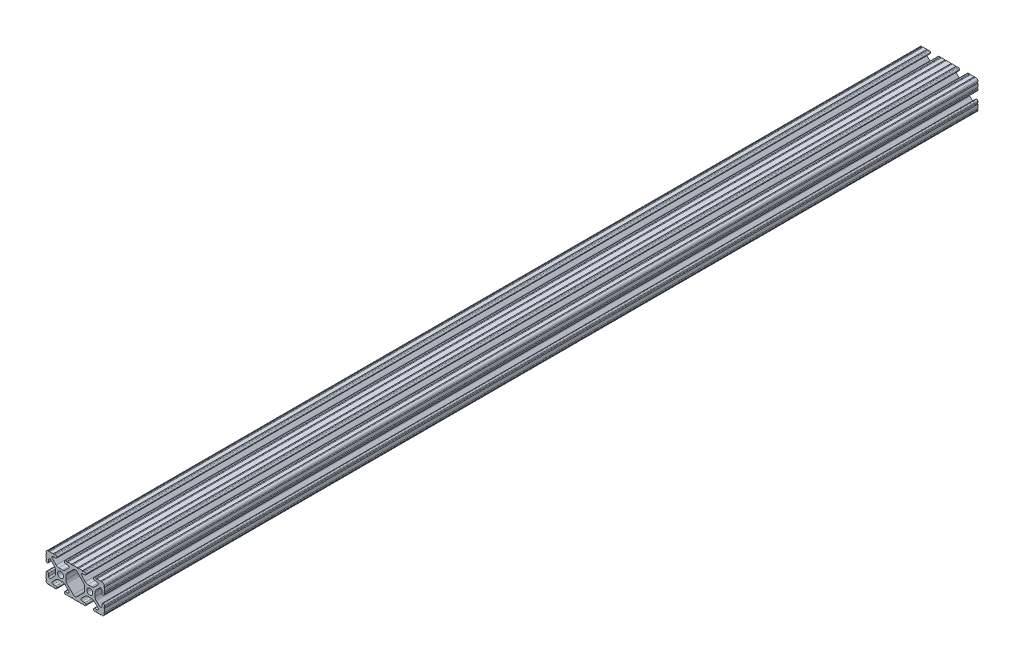
from build123d import *

# Parameters (mm, degrees)
SKETCH1_R      = 2.6035
EXTRUDE1_DEPTH = 760.984


with BuildPart() as part:
    # Sketch1 → Extrude1 (new body)
    with BuildSketch(Plane.XY):
        with BuildLine():
            Line((22.2504, 12.7), (19.03310265, 12.7))
            ThreePointArc((19.03310265, 12.7), (18.52510265, 12.192), (18.01710265, 12.7))
            Line((18.01710265, 12.7), (16.98745015, 12.7))
            ThreePointArc((16.98745015, 12.7), (16.245730386, 12.392769614), (15.9385, 11.65104985))
            Line((15.9385, 11.65104985), (15.9385, 11.53922))
            ThreePointArc((15.9385, 11.53922), (16.245750844, 10.797450844), (16.98752, 10.4902))
            Line((16.98752, 10.4902), (19.116384363, 10.4902))
            ThreePointArc((19.116384363, 10.4902), (20.052502933, 9.869096983), (19.844087081, 8.765172272))
            Line((19.844087081, 8.765172272), (16.618993479, 5.455112286))
            ThreePointArc((16.618993479, 5.455112286), (15.578994274, 4.745442459), (14.344932584, 4.4958))
            Line((14.344932584, 4.4958), (11.083317835, 4.4958))
            ThreePointArc((11.083317835, 4.4958), (9.854330953, 4.743306833), (8.816955189, 5.447238587))
            Line((8.816955189, 5.447238587), (5.564154119, 8.762652677))
            ThreePointArc((5.564154119, 8.762652677), (5.352591412, 9.867473037), (6.289393385, 10.4902))
            Line((6.289393385, 10.4902), (8.41248, 10.4902))
            ThreePointArc((8.41248, 10.4902), (9.154249156, 10.797450844), (9.4615, 11.53922))
            Line((9.4615, 11.53922), (9.4615, 11.65104985))
            ThreePointArc((9.4615, 11.65104985), (9.154269614, 12.392769614), (8.41254985, 12.7))
            Line((8.41254985, 12.7), (7.38288465, 12.7))
            ThreePointArc((7.38288465, 12.7), (6.87488465, 12.192), (6.36688465, 12.7))
            Line((6.36688465, 12.7), (3.14958095, 12.7))
            ThreePointArc((3.14958095, 12.7), (2.64158095, 12.192), (2.13358095, 12.7))
            Line((2.13358095, 12.7), (-2.13358095, 12.7))
            ThreePointArc((-2.13358095, 12.7), (-2.64158095, 12.192), (-3.14958095, 12.7))
            Line((-3.14958095, 12.7), (-6.36689735, 12.7))
            ThreePointArc((-6.36689735, 12.7), (-6.87489735, 12.192), (-7.38289735, 12.7))
            Line((-7.38289735, 12.7), (-8.41254985, 12.7))
            ThreePointArc((-8.41254985, 12.7), (-9.154269614, 12.392769614), (-9.4615, 11.65104985))
            Line((-9.4615, 11.65104985), (-9.4615, 11.53922))
            ThreePointArc((-9.4615, 11.53922), (-9.154249156, 10.797450844), (-8.41248, 10.4902))
            Line((-8.41248, 10.4902), (-6.283641037, 10.4902))
            ThreePointArc((-6.283641037, 10.4902), (-5.297291557, 9.829633109), (-5.532576693, 8.666071843))
            Line((-5.532576693, 8.666071843), (-8.809985098, 5.416263103))
            ThreePointArc((-8.809985098, 5.416263103), (-9.836720513, 4.734920264), (-11.045536121, 4.4958))
            Line((-11.045536121, 4.4958), (-14.354463879, 4.4958))
            ThreePointArc((-14.354463879, 4.4958), (-15.563279487, 4.734920264), (-16.590014902, 5.416263103))
            Line((-16.590014902, 5.416263103), (-19.867423307, 8.666071843))
            ThreePointArc((-19.867423307, 8.666071843), (-20.102708443, 9.829633109), (-19.116358963, 10.4902))
            Line((-19.116358963, 10.4902), (-16.98752, 10.4902))
            ThreePointArc((-16.98752, 10.4902), (-16.245750844, 10.797450844), (-15.9385, 11.53922))
            Line((-15.9385, 11.53922), (-15.9385, 11.65104985))
            ThreePointArc((-15.9385, 11.65104985), (-16.245730386, 12.392769614), (-16.98745015, 12.7))
            Line((-16.98745015, 12.7), (-18.01711535, 12.7))
            ThreePointArc((-18.01711535, 12.7), (-18.52511535, 12.192), (-19.03311535, 12.7))
            Line((-19.03311535, 12.7), (-22.2504, 12.7))
            ThreePointArc((-22.2504, 12.7), (-22.758323491, 12.192000006), (-23.266399977, 12.699846982))
            ThreePointArc((-23.266399977, 12.699846982), (-24.782522516, 12.082522516), (-25.399846982, 10.566399977))
            ThreePointArc((-25.399846982, 10.566399977), (-24.892000006, 10.058323491), (-25.4, 9.5504))
            Line((-25.4, 9.5504), (-25.4, 6.3330836))
            ThreePointArc((-25.4, 6.3330836), (-24.892, 5.8250836), (-25.4, 5.3170836))
            Line((-25.4, 5.3170836), (-25.4, 4.237520184))
            ThreePointArc((-25.4, 4.237520184), (-25.107393763, 3.531106237), (-24.400979816, 3.2385))
            Line((-24.400979816, 3.2385), (-24.23922, 3.2385))
            ThreePointArc((-24.23922, 3.2385), (-23.497450844, 3.545750844), (-23.1902, 4.28752))
            Line((-23.1902, 4.28752), (-23.1902, 6.334741132))
            ThreePointArc((-23.1902, 6.334741132), (-22.556026952, 7.286023527), (-21.434002553, 7.066535717))
            Line((-21.434002553, 7.066535717), (-18.147950853, 3.808156468))
            ThreePointArc((-18.147950853, 3.808156468), (-17.452759693, 2.774838327), (-17.208501877, 1.553619571))
            Line((-17.208501877, 1.553619571), (-17.208501877, -1.695179196))
            ThreePointArc((-17.208501877, -1.695179196), (-17.450738657, -2.911536421), (-18.140486065, -3.942289578))
            Line((-18.140486065, -3.942289578), (-21.431579576, -7.227386226))
            ThreePointArc((-21.431579576, -7.227386226), (-22.55444896, -7.449940594), (-23.1902, -6.498002195))
            Line((-23.1902, -6.498002195), (-23.1902, -4.28752))
            ThreePointArc((-23.1902, -4.28752), (-23.497450844, -3.545750844), (-24.23922, -3.2385))
            Line((-24.23922, -3.2385), (-24.35098, -3.2385))
            ThreePointArc((-24.35098, -3.2385), (-25.092749156, -3.545750844), (-25.4, -4.28752))
            Line((-25.4, -4.28752), (-25.4, -5.3171344))
            ThreePointArc((-25.4, -5.3171344), (-24.892, -5.8251344), (-25.4, -6.3331344))
            Line((-25.4, -6.3331344), (-25.4, -9.5504))
            ThreePointArc((-25.4, -9.5504), (-24.892000006, -10.058323491), (-25.399846982, -10.566399977))
            ThreePointArc((-25.399846982, -10.566399977), (-24.782522516, -12.082522516), (-23.266399977, -12.699846982))
            ThreePointArc((-23.266399977, -12.699846982), (-22.758323491, -12.192000006), (-22.2504, -12.7))
            Line((-22.2504, -12.7), (-19.03308995, -12.7))
            ThreePointArc((-19.03308995, -12.7), (-18.52508995, -12.192), (-18.01708995, -12.7))
            Line((-18.01708995, -12.7), (-16.9874692, -12.7))
            ThreePointArc((-16.9874692, -12.7), (-16.245700044, -12.392749156), (-15.9384492, -11.65098))
            Line((-15.9384492, -11.65098), (-15.9384492, -11.53922))
            ThreePointArc((-15.9384492, -11.53922), (-16.245700044, -10.797450844), (-16.9874692, -10.4902))
            Line((-16.9874692, -10.4902), (-19.116358963, -10.4902))
            ThreePointArc((-19.116358963, -10.4902), (-20.055197748, -9.862578342), (-19.834124023, -8.755124678))
            Line((-19.834124023, -8.755124678), (-16.49660751, -5.423689618))
            ThreePointArc((-16.49660751, -5.423689618), (-15.467274017, -4.736928798), (-14.253591699, -4.4958))
            Line((-14.253591699, -4.4958), (-11.146408301, -4.4958))
            ThreePointArc((-11.146408301, -4.4958), (-9.932725983, -4.736928798), (-8.90339249, -5.423689618))
            Line((-8.90339249, -5.423689618), (-5.565875977, -8.755124678))
            ThreePointArc((-5.565875977, -8.755124678), (-5.344802252, -9.862578342), (-6.283641037, -10.4902))
            Line((-6.283641037, -10.4902), (-8.4125308, -10.4902))
            ThreePointArc((-8.4125308, -10.4902), (-9.154299956, -10.797450844), (-9.4615508, -11.53922))
            Line((-9.4615508, -11.53922), (-9.4615508, -11.65098))
            ThreePointArc((-9.4615508, -11.65098), (-9.154299956, -12.392749156), (-8.4125308, -12.7))
            Line((-8.4125308, -12.7), (-7.38287195, -12.7))
            ThreePointArc((-7.38287195, -12.7), (-6.87487195, -12.192), (-6.36687195, -12.7))
            Line((-6.36687195, -12.7), (-3.14960635, -12.7))
            ThreePointArc((-3.14960635, -12.7), (-2.64160635, -12.192), (-2.13360635, -12.7))
            Line((-2.13360635, -12.7), (2.13360635, -12.7))
            ThreePointArc((2.13360635, -12.7), (2.64159365, -12.1920127), (3.14958095, -12.7))
            Line((3.14958095, -12.7), (6.36691005, -12.7))
            ThreePointArc((6.36691005, -12.7), (6.87491005, -12.192), (7.38291005, -12.7))
            Line((7.38291005, -12.7), (8.4125308, -12.7))
            ThreePointArc((8.4125308, -12.7), (9.154299956, -12.392749156), (9.4615508, -11.65098))
            Line((9.4615508, -11.65098), (9.4615508, -11.53922))
            ThreePointArc((9.4615508, -11.53922), (9.154299956, -10.797450844), (8.4125308, -10.4902))
            Line((8.4125308, -10.4902), (6.289393385, -10.4902))
            ThreePointArc((6.289393385, -10.4902), (5.231590322, -9.783049717), (5.480677245, -8.535265862))
            Line((5.480677245, -8.535265862), (8.597933595, -5.423689618))
            ThreePointArc((8.597933595, -5.423689618), (9.627267088, -4.736928798), (10.840949406, -4.4958))
            Line((10.840949406, -4.4958), (14.102564155, -4.4958))
            ThreePointArc((14.102564155, -4.4958), (15.215927525, -4.697410182), (16.187895372, -5.276636531))
            Line((16.187895372, -5.276636531), (19.868247549, -8.482246082))
            ThreePointArc((19.868247549, -8.482246082), (20.188435806, -9.746879864), (19.116384363, -10.4902))
            Line((19.116384363, -10.4902), (16.9874692, -10.4902))
            ThreePointArc((16.9874692, -10.4902), (16.245700044, -10.797450844), (15.9384492, -11.53922))
            Line((15.9384492, -11.53922), (15.9384492, -11.65098))
            ThreePointArc((15.9384492, -11.65098), (16.245700044, -12.392749156), (16.9874692, -12.7))
            Line((16.9874692, -12.7), (18.01710265, -12.7))
            ThreePointArc((18.01710265, -12.7), (18.52510265, -12.192), (19.03310265, -12.7))
            Line((19.03310265, -12.7), (22.2504, -12.7))
            ThreePointArc((22.2504, -12.7), (22.758323491, -12.192000006), (23.266399977, -12.699846982))
            ThreePointArc((23.266399977, -12.699846982), (24.782522516, -12.082522516), (25.399846982, -10.566399977))
            ThreePointArc((25.399846982, -10.566399977), (24.892000006, -10.058323492), (25.4, -9.550400001))
            Line((25.4, -9.550400001), (25.4, -6.333083592))
            ThreePointArc((25.4, -6.333083592), (24.892000001, -5.825083593), (25.4, -5.317083593))
            Line((25.4, -5.317083593), (25.4, -4.237520184))
            ThreePointArc((25.4, -4.237520184), (25.107393763, -3.531106237), (24.400979816, -3.2385))
            Line((24.400979816, -3.2385), (24.189220184, -3.2385))
            ThreePointArc((24.189220184, -3.2385), (23.482806237, -3.531106237), (23.1902, -4.237520184))
            Line((23.1902, -4.237520184), (23.1902, -6.155876159))
            ThreePointArc((23.1902, -6.155876159), (22.62232736, -7.038258539), (21.583974541, -6.886926384))
            Line((21.583974541, -6.886926384), (18.29817066, -4.024970844))
            ThreePointArc((18.29817066, -4.024970844), (17.493730985, -2.946044689), (17.208501877, -1.630807374))
            Line((17.208501877, -1.630807374), (17.208501877, 1.630807374))
            ThreePointArc((17.208501877, 1.630807374), (17.442348332, 2.82673414), (18.109440981, 3.846495088))
            Line((18.109440981, 3.846495088), (21.526346532, 7.353420386))
            ThreePointArc((21.526346532, 7.353420386), (22.585896263, 7.574939077), (23.1902, 6.676867167))
            Line((23.1902, 6.676867167), (23.1902, 4.237520184))
            ThreePointArc((23.1902, 4.237520184), (23.482806237, 3.531106237), (24.189220184, 3.2385))
            Line((24.189220184, 3.2385), (24.400979816, 3.2385))
            ThreePointArc((24.400979816, 3.2385), (25.107393763, 3.531106237), (25.4, 4.237520184))
            Line((25.4, 4.237520184), (25.4, 5.3170836))
            ThreePointArc((25.4, 5.3170836), (24.891949193, 5.825134407), (25.4, 6.333185215))
            Line((25.4, 6.333185215), (25.4, 9.550400015))
            ThreePointArc((25.4, 9.550400015), (24.892000013, 10.058323498), (25.399846982, 10.566399977))
            ThreePointArc((25.399846982, 10.566399977), (24.782522516, 12.082522516), (23.266399977, 12.699846982))
            ThreePointArc((23.266399977, 12.699846982), (22.758323491, 12.192000006), (22.2504, 12.7))
        make_face()
        with Locations((-12.7, 0)):
            Circle(SKETCH1_R, mode=Mode.SUBTRACT)
        with Locations((12.7, 0)):
            Circle(SKETCH1_R, mode=Mode.SUBTRACT)
        with BuildLine():
            Line((-7.259513935, -3.869413038), (-1.545748891, -9.572766749))
            ThreePointArc((-1.545748891, -9.572766749), (-1.035199478, -9.913400116), (-0.433213048, -10.033))
            Line((-0.433213048, -10.033), (0.433213048, -10.033))
            ThreePointArc((0.433213048, -10.033), (1.035199478, -9.913400116), (1.545748891, -9.572766749))
            Line((1.545748891, -9.572766749), (7.259513935, -3.869413038))
            ThreePointArc((7.259513935, -3.869413038), (7.949261343, -2.838659881), (8.191498123, -1.622302656))
            Line((8.191498123, -1.622302656), (8.191498123, 1.622302656))
            ThreePointArc((8.191498123, 1.622302656), (7.955573352, 2.823327967), (7.282860769, 3.845864069))
            Line((7.282860769, 3.845864069), (1.675572808, 9.561086461))
            ThreePointArc((1.675572808, 9.561086461), (1.161034429, 9.910236611), (0.551456936, 10.033))
            Line((0.551456936, 10.033), (-0.395199982, 10.033))
            ThreePointArc((-0.395199982, 10.033), (-0.994772524, 9.914396349), (-1.50403329, 9.576450301))
            Line((-1.50403329, 9.576450301), (-7.252049147, 3.876839553))
            ThreePointArc((-7.252049147, 3.876839553), (-7.947240307, 2.843521412), (-8.191498123, 1.622302656))
            Line((-8.191498123, 1.622302656), (-8.191498123, -1.622302656))
            ThreePointArc((-8.191498123, -1.622302656), (-7.949261343, -2.838659881), (-7.259513935, -3.869413038))
        make_face(mode=Mode.SUBTRACT)
    extrude(amount=-EXTRUDE1_DEPTH)


solid = part.part
